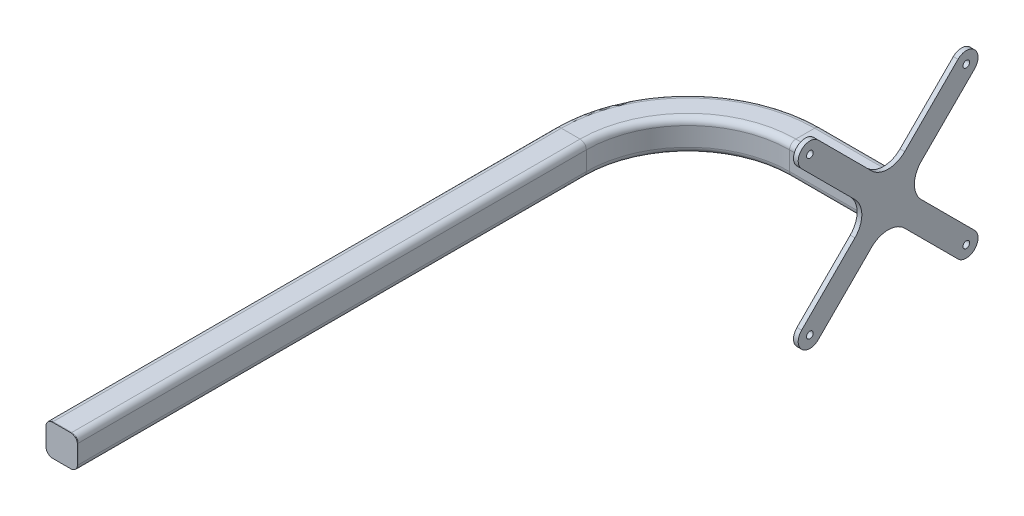
from build123d import *

# Parameters (mm, degrees)
SQUARE_TUBE_40_X_40_X_4_1_DEPTH   = 650
SQUARE_TUBE_40_X_40_X_4_1_2_ANGLE = 90
SQUARE_TUBE_40_X_40_X_4_1_3_DEPTH = 100
BOSS_EXTRUDE1_DEPTH               = 1
SKETCH13_R                        = 4.25
BOSS_EXTRUDE2_DEPTH               = 6


with BuildPart() as part:
    # Sketch11 → Square tube 40 X 40 X 4(1) (new body)
    with BuildSketch(Plane(origin=(0, 0, 0), x_dir=(-1, 0, 0), z_dir=(0, 0, -1))):
        with BuildLine():
            Line((-12, -20), (12, -20))
            ThreePointArc((12, -20), (17.656854249, -17.656854249), (20, -12))
            Line((20, -12), (20, 12))
            ThreePointArc((20, 12), (17.656854249, 17.656854249), (12, 20))
            Line((12, 20), (-12, 20))
            ThreePointArc((-12, 20), (-17.656854249, 17.656854249), (-20, 12))
            Line((-20, 12), (-20, -12))
            ThreePointArc((-20, -12), (-17.656854249, -17.656854249), (-12, -20))
        make_face()
        with BuildLine():
            Line((-12, -16), (12, -16))
            ThreePointArc((12, -16), (14.828427125, -14.828427125), (16, -12))
            Line((16, -12), (16, 12))
            ThreePointArc((16, 12), (14.828427125, 14.828427125), (12, 16))
            Line((12, 16), (-12, 16))
            ThreePointArc((-12, 16), (-14.828427125, 14.828427125), (-16, 12))
            Line((-16, 12), (-16, -12))
            ThreePointArc((-16, -12), (-14.828427125, -14.828427125), (-12, -16))
        make_face(mode=Mode.SUBTRACT)
    extrude(amount=SQUARE_TUBE_40_X_40_X_4_1_DEPTH)


with BuildPart() as body_2:
    # Sketch11 on segment 2 (carried to the start of arc 2) → Square tube 40 X 40 X 4_1 2 (revolve)
    with BuildSketch(Plane(origin=(0, 0, -650), x_dir=(-1, 0, 0), z_dir=(0, 0, -1))):
        with BuildLine():
            Line((-12, -20), (12, -20))
            ThreePointArc((12, -20), (17.656854249, -17.656854249), (20, -12))
            Line((20, -12), (20, 12))
            ThreePointArc((20, 12), (17.656854249, 17.656854249), (12, 20))
            Line((12, 20), (-12, 20))
            ThreePointArc((-12, 20), (-17.656854249, 17.656854249), (-20, 12))
            Line((-20, 12), (-20, -12))
            ThreePointArc((-20, -12), (-17.656854249, -17.656854249), (-12, -20))
        make_face()
        with BuildLine():
            Line((-12, -16), (12, -16))
            ThreePointArc((12, -16), (14.828427125, -14.828427125), (16, -12))
            Line((16, -12), (16, 12))
            ThreePointArc((16, 12), (14.828427125, 14.828427125), (12, 16))
            Line((12, 16), (-12, 16))
            ThreePointArc((-12, 16), (-14.828427125, 14.828427125), (-16, 12))
            Line((-16, 12), (-16, -12))
            ThreePointArc((-16, -12), (-14.828427125, -14.828427125), (-12, -16))
        make_face(mode=Mode.SUBTRACT)
    revolve(axis=Axis((150, 0, -650), (0, -1, 0)), revolution_arc=SQUARE_TUBE_40_X_40_X_4_1_2_ANGLE)


with BuildPart() as body_3:
    # Sketch11 on segment 3 (carried to segment 3) → Square tube 40 X 40 X 4_1 3 (new body)
    with BuildSketch(Plane(origin=(150, 0, -800), x_dir=(0, 0, -1), z_dir=(1, 0, 0))):
        with BuildLine():
            Line((-12, -20), (12, -20))
            ThreePointArc((12, -20), (17.656854249, -17.656854249), (20, -12))
            Line((20, -12), (20, 12))
            ThreePointArc((20, 12), (17.656854249, 17.656854249), (12, 20))
            Line((12, 20), (-12, 20))
            ThreePointArc((-12, 20), (-17.656854249, 17.656854249), (-20, 12))
            Line((-20, 12), (-20, -12))
            ThreePointArc((-20, -12), (-17.656854249, -17.656854249), (-12, -20))
        make_face()
        with BuildLine():
            Line((-12, -16), (12, -16))
            ThreePointArc((12, -16), (14.828427125, -14.828427125), (16, -12))
            Line((16, -12), (16, 12))
            ThreePointArc((16, 12), (14.828427125, 14.828427125), (12, 16))
            Line((12, 16), (-12, 16))
            ThreePointArc((-12, 16), (-14.828427125, 14.828427125), (-16, 12))
            Line((-16, 12), (-16, -12))
            ThreePointArc((-16, -12), (-14.828427125, -14.828427125), (-12, -16))
        make_face(mode=Mode.SUBTRACT)
    extrude(amount=SQUARE_TUBE_40_X_40_X_4_1_3_DEPTH)


with BuildPart() as body_4:
    # Sketch12 → Boss-Extrude1 (new body)
    with BuildSketch(Plane.XY):
        with BuildLine():
            Line((-11.580971912, -20), (11.580971912, -20))
            ThreePointArc((11.580971912, -20), (17.591379552, -17.51040764), (20.080971912, -11.5))
            Line((20.080971912, -11.5), (20.080971912, 11.5))
            ThreePointArc((20.080971912, 11.5), (17.591379552, 17.51040764), (11.580971912, 20))
            Line((11.580971912, 20), (-11.580971912, 20))
            ThreePointArc((-11.580971912, 20), (-17.591379552, 17.51040764), (-20.080971912, 11.5))
            Line((-20.080971912, 11.5), (-20.080971912, -11.5))
            ThreePointArc((-20.080971912, -11.5), (-17.591379552, -17.51040764), (-11.580971912, -20))
        make_face()
    extrude(amount=BOSS_EXTRUDE1_DEPTH)


with BuildPart() as body_5:
    # Sketch13 → Boss-Extrude2 (new body)
    with BuildSketch(Plane(origin=(250, 0, 0), x_dir=(0, 0, -1), z_dir=(1, 0, 0))):
        with BuildLine():
            Line((842.426406871, 21.213203436), (910.606601718, 89.393398282))
            ThreePointArc((910.606601718, 89.393398282), (910.606601718, 110.606601718), (889.393398282, 110.606601718))
            Line((889.393398282, 110.606601718), (821.213203436, 42.426406871))
            ThreePointArc((821.213203436, 42.426406871), (800, 33.639610307), (778.786796564, 42.426406871))
            Line((778.786796564, 42.426406871), (710.606601718, 110.606601718))
            ThreePointArc((710.606601718, 110.606601718), (689.393398282, 110.606601718), (689.393398282, 89.393398282))
            Line((689.393398282, 89.393398282), (757.573593129, 21.213203436))
            ThreePointArc((757.573593129, 21.213203436), (766.360389693, 0), (757.573593129, -21.213203436))
            Line((757.573593129, -21.213203436), (689.393398282, -89.393398282))
            ThreePointArc((689.393398282, -89.393398282), (689.393398282, -110.606601718), (710.606601718, -110.606601718))
            Line((710.606601718, -110.606601718), (778.786796564, -42.426406871))
            ThreePointArc((778.786796564, -42.426406871), (800, -33.639610307), (821.213203436, -42.426406871))
            Line((821.213203436, -42.426406871), (889.393398282, -110.606601718))
            ThreePointArc((889.393398282, -110.606601718), (910.606601718, -110.606601718), (910.606601718, -89.393398282))
            Line((910.606601718, -89.393398282), (842.426406871, -21.213203436))
            ThreePointArc((842.426406871, -21.213203436), (833.639610307, 0), (842.426406871, 21.213203436))
        make_face()
        with Locations((900, 100)):
            Circle(SKETCH13_R, mode=Mode.SUBTRACT)
        with Locations((900, -100)):
            Circle(SKETCH13_R, mode=Mode.SUBTRACT)
        with Locations((700, -100)):
            Circle(SKETCH13_R, mode=Mode.SUBTRACT)
        with Locations((700, 100)):
            Circle(SKETCH13_R, mode=Mode.SUBTRACT)
    extrude(amount=BOSS_EXTRUDE2_DEPTH)


solid = Compound([part.part, body_2.part, body_3.part, body_4.part, body_5.part])
